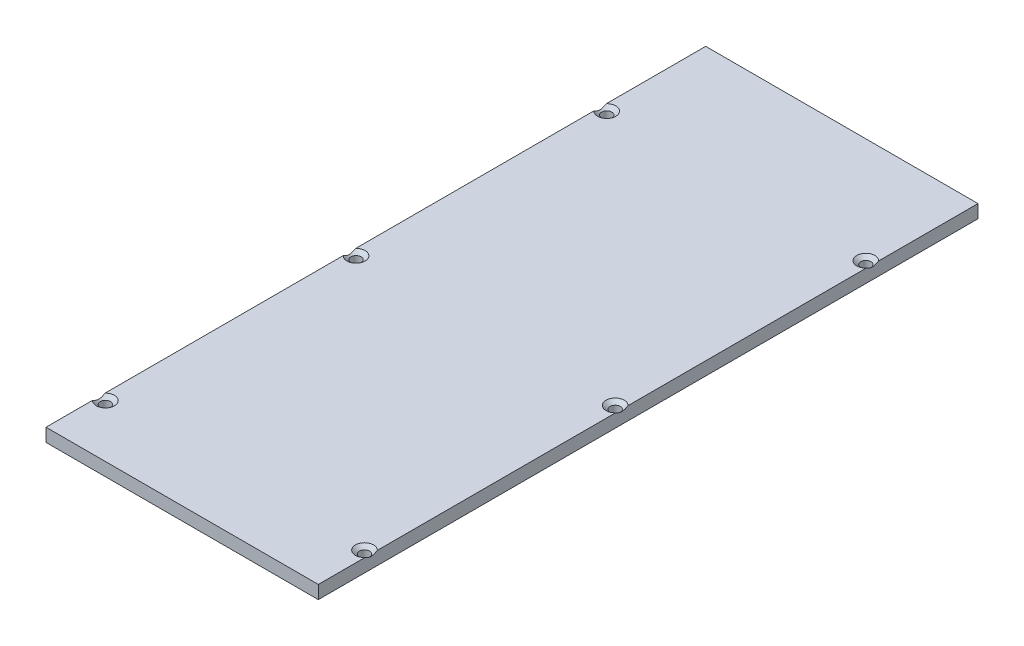
from build123d import *

# Parameters (mm, degrees)
SKETCH1_W                                         = 65.532
SKETCH1_H                                         = 158.75
EXTRUDE1_DEPTH                                    = 3.175
CSK_FOR_2_FLAT_HEAD_MACHINE_SCREW_100_D           = 2.4384
CSK_FOR_2_FLAT_HEAD_MACHINE_SCREW_100_CSINK_D     = 4.3688
CSK_FOR_2_FLAT_HEAD_MACHINE_SCREW_100_CSINK_ANGLE = 100
TAP_DRILL_FOR_2_TAP1_D                            = 1.778
TAP_DRILL_FOR_2_TAP1_DEPTH                        = 6.35
TAP_DRILL_FOR_2_TAP1_TIP                          = 0.53416509


with BuildPart() as part:
    # Sketch1 → Extrude1 (new body)
    with BuildSketch(Plane(origin=(0, 0, 0), x_dir=(1, 0, 0), z_dir=(0, 1, 0))):
        Rectangle(SKETCH1_W, SKETCH1_H)
    extrude(amount=EXTRUDE1_DEPTH)

    # CSK for #2 Flat Head Machine Screw (100)1 (through all)
    with Locations(Plane(origin=(-31.1785, 3.175, -53.975), x_dir=(0, 0, 1), z_dir=(0, 1, 0))):
        with Locations((0, 0), (120.65, 0), (60.325, 0), (0, 62.357), (60.325, 62.357), (120.65, 62.357)):
            CounterSinkHole(CSK_FOR_2_FLAT_HEAD_MACHINE_SCREW_100_D / 2, CSK_FOR_2_FLAT_HEAD_MACHINE_SCREW_100_CSINK_D / 2, counter_sink_angle=CSK_FOR_2_FLAT_HEAD_MACHINE_SCREW_100_CSINK_ANGLE)

    # Tap Drill for #2 Tap1
    with Locations(Plane(origin=(-26.416, 1.5875, -79.375), x_dir=(-1, 0, 0), z_dir=(0, 0, -1))):
        with Locations((0, 0), (-52.832, 0)):
            Hole(TAP_DRILL_FOR_2_TAP1_D / 2, depth=TAP_DRILL_FOR_2_TAP1_DEPTH)
            with Locations((0, 0, -(TAP_DRILL_FOR_2_TAP1_DEPTH + TAP_DRILL_FOR_2_TAP1_TIP / 2))):  # 118° drill point
                Cone(0, TAP_DRILL_FOR_2_TAP1_D / 2, TAP_DRILL_FOR_2_TAP1_TIP, mode=Mode.SUBTRACT)


solid = part.part
